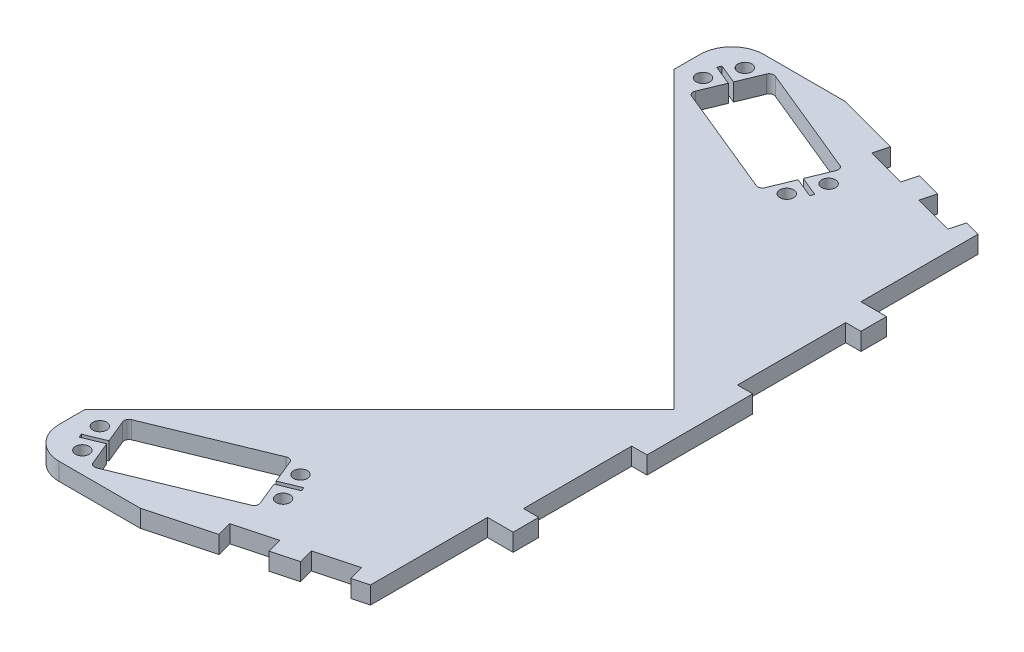
from build123d import *

# Parameters (mm, degrees)
SKETCH1_R           = 2.15
BOSS_EXTRUDE1_DEPTH = 5.461
FILLET1_R           = 10
SKETCH2_W           = 4.7625
SKETCH2_H           = 33.783
CUT_EXTRUDE1_DEPTH  = 10


with BuildPart() as part:
    # Sketch1 → Boss-Extrude1 (new body)
    with BuildSketch(Plane(origin=(0, 0, 0), x_dir=(1, 0, 0), z_dir=(0, 1, 0))):
        Polygon((0, 0), (-92, 92), (-92, 110), (-56.601944845, 110), (0, 94.833554589), (0, 58.293), (8, 58.293), (8, -58.293), (0, -58.293), (0, -94.833554589), (-56.601944845, -110), (-92, -110), (-92, -92), align=None)
        with Locations((-85.159917522, 94.147890435)):
            Circle(SKETCH1_R, mode=Mode.SUBTRACT)
        with Locations((-81.358825255, 103.397306502)):
            Circle(SKETCH1_R, mode=Mode.SUBTRACT)
        with Locations((-36.961628134, 85.152063619)):
            Circle(SKETCH1_R, mode=Mode.SUBTRACT)
        with Locations((-40.762720402, 75.902647552)):
            Circle(SKETCH1_R, mode=Mode.SUBTRACT)
        with Locations((-40.762720402, -75.902647552)):
            Circle(SKETCH1_R, mode=Mode.SUBTRACT)
        with Locations((-36.961628134, -85.152063619)):
            Circle(SKETCH1_R, mode=Mode.SUBTRACT)
        with Locations((-81.358825255, -103.397306502)):
            Circle(SKETCH1_R, mode=Mode.SUBTRACT)
        with Locations((-85.159917522, -94.147890435)):
            Circle(SKETCH1_R, mode=Mode.SUBTRACT)
        with BuildLine():
            Line((-79.322036695, 97.830250065), (-76.328676535, 105.114165218))
            ThreePointArc((-76.328676535, 105.114165218), (-76.087243425, 105.511850251), (-75.735570504, 105.816431091))
            ThreePointArc((-75.735570504, 105.816431091), (-75.067221358, 106.038703614), (-74.371100284, 105.931413788))
            Line((-74.371100284, 105.931413788), (-40.148260837, 91.867372399))
            ThreePointArc((-40.148260837, 91.867372399), (-39.577853455, 91.454176231), (-39.258927152, 90.826178087))
            ThreePointArc((-39.258927152, 90.826178087), (-39.223044121, 90.362329254), (-39.331012268, 89.909796149))
            Line((-39.331012268, 89.909796149), (-42.324372428, 82.625880996))
            Line((-42.324372428, 82.625880996), (-36.219757824, 80.1171601))
            Line((-36.219757824, 80.1171601), (-36.694894357, 78.960983092))
            Line((-36.694894357, 78.960983092), (-42.799508961, 81.469703988))
            Line((-42.799508961, 81.469703988), (-45.792869122, 74.185788836))
            ThreePointArc((-45.792869122, 74.185788836), (-46.034302231, 73.788103802), (-46.385975153, 73.483522962))
            ThreePointArc((-46.385975153, 73.483522962), (-47.054324299, 73.261250439), (-47.750445372, 73.368540266))
            Line((-47.750445372, 73.368540266), (-81.973284819, 87.432581654))
            ThreePointArc((-81.973284819, 87.432581654), (-82.543692202, 87.845777823), (-82.862618505, 88.473775966))
            ThreePointArc((-82.862618505, 88.473775966), (-82.898501536, 88.937624799), (-82.790533389, 89.390157905))
            Line((-82.790533389, 89.390157905), (-79.797173228, 96.674073057))
            Line((-79.797173228, 96.674073057), (-85.901787832, 99.182793954))
            Line((-85.901787832, 99.182793954), (-85.426651299, 100.338970962))
            Line((-85.426651299, 100.338970962), (-79.322036695, 97.830250065))
        make_face(mode=Mode.SUBTRACT)
        with BuildLine():
            Line((-47.750445372, -73.368540266), (-81.973284819, -87.432581654))
            ThreePointArc((-81.973284819, -87.432581654), (-82.543692202, -87.845777823), (-82.862618505, -88.473775966))
            ThreePointArc((-82.862618505, -88.473775966), (-82.898501536, -88.937624799), (-82.790533389, -89.390157905))
            Line((-82.790533389, -89.390157905), (-79.797173228, -96.674073057))
            Line((-79.797173228, -96.674073057), (-85.901787832, -99.182793954))
            Line((-85.901787832, -99.182793954), (-85.426651299, -100.338970962))
            Line((-85.426651299, -100.338970962), (-79.322036695, -97.830250065))
            Line((-79.322036695, -97.830250065), (-76.328676535, -105.114165218))
            ThreePointArc((-76.328676535, -105.114165218), (-76.087243425, -105.511850251), (-75.735570504, -105.816431091))
            ThreePointArc((-75.735570504, -105.816431091), (-75.067221358, -106.038703614), (-74.371100284, -105.931413788))
            Line((-74.371100284, -105.931413788), (-40.148260837, -91.867372399))
            ThreePointArc((-40.148260837, -91.867372399), (-39.577853455, -91.454176231), (-39.258927152, -90.826178087))
            ThreePointArc((-39.258927152, -90.826178087), (-39.223044121, -90.362329254), (-39.331012268, -89.909796149))
            Line((-39.331012268, -89.909796149), (-42.324372428, -82.625880996))
            Line((-42.324372428, -82.625880996), (-36.219757824, -80.1171601))
            Line((-36.219757824, -80.1171601), (-36.694894357, -78.960983092))
            Line((-36.694894357, -78.960983092), (-42.799508961, -81.469703988))
            Line((-42.799508961, -81.469703988), (-45.792869122, -74.185788836))
            ThreePointArc((-45.792869122, -74.185788836), (-46.034302231, -73.788103802), (-46.385975153, -73.483522962))
            ThreePointArc((-46.385975153, -73.483522962), (-47.054324299, -73.261250439), (-47.750445372, -73.368540266))
        make_face(mode=Mode.SUBTRACT)
    extrude(amount=BOSS_EXTRUDE1_DEPTH)

    # Fillet1
    fillet1_edges = [part.edges().sort_by_distance(p)[0] for p in [
        (-92, 2.7305, 110),
        (-92, 2.7305, -110),
    ]]
    fillet(fillet1_edges, radius=FILLET1_R)

    # Sketch2 → Cut-Extrude1 (cut)
    with BuildSketch(Plane(origin=(0, 0, 0), x_dir=(1, 0, 0), z_dir=(0, 1, 0))):
        Polygon((-4.829629131, 96.127649814), (-17.19282542, 99.440358276), (-18.425451123, 94.840136528), (-6.062254834, 91.527428067), align=None)
        Polygon((-24.920232031, 101.510910637), (-37.283428319, 104.823619098), (-38.516054022, 100.22339735), (-26.152857733, 96.910688889), align=None)
        Polygon((-26.152857733, -96.910688889), (-38.516054022, -100.22339735), (-37.283428319, -104.823619098), (-24.920232031, -101.510910637), align=None)
        Polygon((-6.062254834, -91.527428067), (-18.425451123, -94.840136528), (-17.19282542, -99.440358276), (-4.829629131, -96.127649814), align=None)
        with Locations((5.61875, 33.4015)):
            Rectangle(SKETCH2_W, SKETCH2_H)
        with Locations((5.61875, -33.4015)):
            Rectangle(SKETCH2_W, SKETCH2_H)
    extrude(amount=CUT_EXTRUDE1_DEPTH, mode=Mode.SUBTRACT)


solid = part.part
